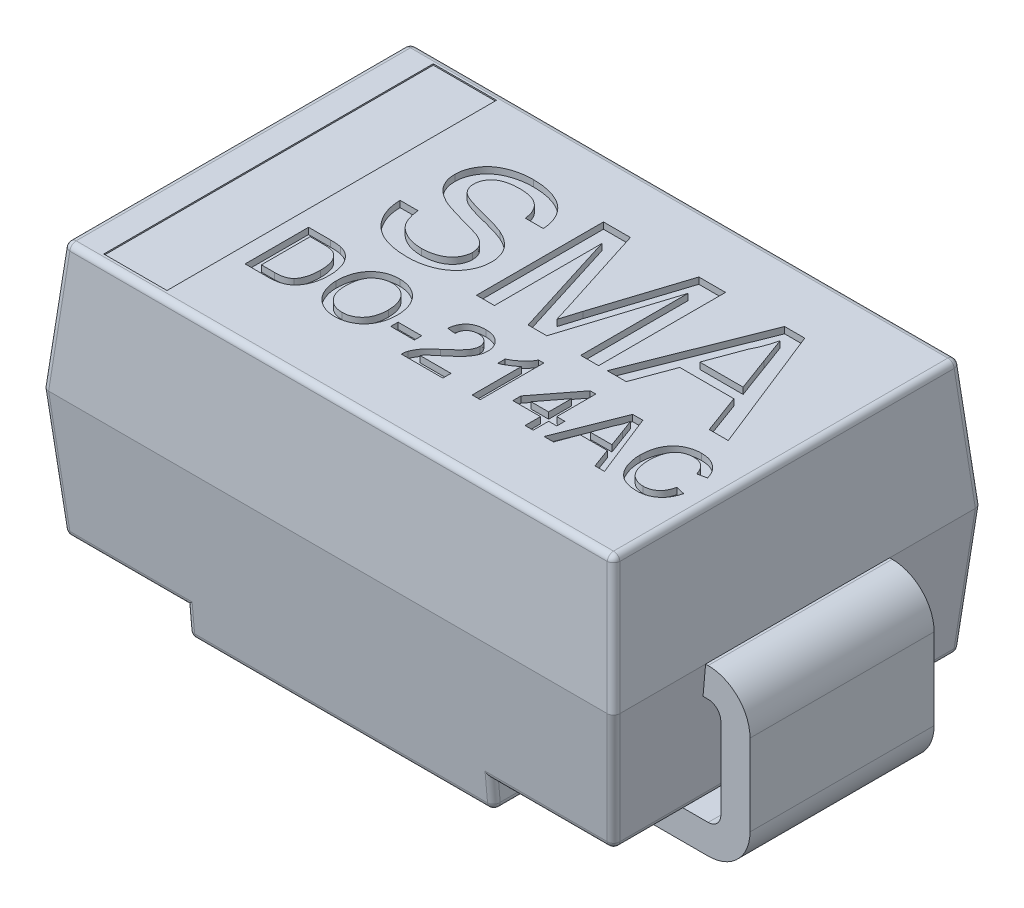
from build123d import *

# Parameters (mm, degrees)
BOSS_EXTRUDE1_START = 1.3
SKETCH1_W           = 4.5
SKETCH1_H           = 2.9
BOSS_EXTRUDE1_DEPTH = 1
BOSS_EXTRUDE1_TAPER = 5
BOSS_EXTRUDE2_START = 1.3
SKETCH1_2_W         = 4.5
SKETCH1_2_H         = 2.9
BOSS_EXTRUDE2_DEPTH = 1.23
BOSS_EXTRUDE2_DRAFT = -5
CUT_EXTRUDE2_DEPTH  = 2
BOSS_EXTRUDE3_DEPTH = 0.725
FILLET1_R           = 0.05
SKETCH5_W           = 0.498176358
SKETCH5_H           = 2.595911432
CUT_EXTRUDE4_DEPTH  = 0.01
SKETCH4_W           = 0.185897436
SKETCH4_H           = 0.057692308
CUT_EXTRUDE3_DEPTH  = 0.05


with BuildPart() as part:
    # Sketch1 → Boss-Extrude1 (new body)
    with BuildSketch(Plane(origin=(0, 0, 0), x_dir=(1, 0, 0), z_dir=(0, 1, 0)).offset(BOSS_EXTRUDE1_START)):
        Rectangle(SKETCH1_W, SKETCH1_H)
    extrude(amount=BOSS_EXTRUDE1_DEPTH, taper=BOSS_EXTRUDE1_TAPER)


with BuildPart() as boss_extrude2_tool:
    # Sketch1_2 → Boss-Extrude2 (with draft: the straight prism first)
    with BuildSketch(Plane(origin=(0, 0, 0), x_dir=(1, 0, 0), z_dir=(0, 1, 0)).offset(BOSS_EXTRUDE2_START)):
        Rectangle(SKETCH1_2_W, SKETCH1_2_H)
    extrude(amount=-BOSS_EXTRUDE2_DEPTH)
    # Boss-Extrude2: the draft: its side faces are tilted about the plane it starts from
    boss_extrude2_sides = [boss_extrude2_tool.faces().sort_by_distance(p)[0] for p in [
        (0, 0.685, 1.45),
        (2.25, 0.685, 0),
        (0, 0.685, -1.45),
        (-2.25, 0.685, 0),
    ]]
    draft(boss_extrude2_sides, Plane(origin=(0, 0, 0), x_dir=(1, 0, 0), z_dir=(0, 1, 0)).offset(BOSS_EXTRUDE2_START), BOSS_EXTRUDE2_DRAFT)


with BuildPart() as part_1:
    add(part.part)

    # Boss-Extrude2: add boss_extrude2_tool
    add(boss_extrude2_tool.part)

    # Sketch3 → Cut-Extrude2 (cut, symmetric)
    with BuildSketch(Plane.XY):
        Polygon((1.203776107, 0), (-1.203776107, 0), (-1.203776107, 0.297017544), (-2.27, 0.297017544), (-2.27, -0.205171261), (2.27, -0.205171261), (2.27, 0.297017544), (1.203776107, 0.297017544), align=None)
    extrude(amount=CUT_EXTRUDE2_DEPTH, both=True, mode=Mode.SUBTRACT)

    # Sketch2 → Boss-Extrude3 (add, symmetric)
    with BuildSketch(Plane.XY):
        with BuildLine():
            Line((2.27, 1.3), (-2.27, 1.3))
            ThreePointArc((-2.27, 1.3), (-2.503345238, 1.203345238), (-2.6, 0.97))
            Line((-2.6, 0.97), (-2.6, 0.33))
            ThreePointArc((-2.6, 0.33), (-2.503345238, 0.096654762), (-2.27, 0))
            Line((-2.27, 0), (-1.36, 0))
            Line((-1.36, 0), (-1.36, 0.23))
            Line((-1.36, 0.23), (-2.27, 0.23))
            ThreePointArc((-2.27, 0.23), (-2.340710678, 0.259289322), (-2.37, 0.33))
            Line((-2.37, 0.33), (-2.37, 0.97))
            ThreePointArc((-2.37, 0.97), (-2.340710678, 1.040710678), (-2.27, 1.07))
            Line((-2.27, 1.07), (2.27, 1.07))
            ThreePointArc((2.27, 1.07), (2.340710678, 1.040710678), (2.37, 0.97))
            Line((2.37, 0.97), (2.37, 0.33))
            ThreePointArc((2.37, 0.33), (2.340710678, 0.259289322), (2.27, 0.23))
            Line((2.27, 0.23), (1.36, 0.23))
            Line((1.36, 0.23), (1.36, 0))
            Line((1.36, 0), (2.27, 0))
            ThreePointArc((2.27, 0), (2.503345238, 0.096654762), (2.6, 0.33))
            Line((2.6, 0.33), (2.6, 0.97))
            ThreePointArc((2.6, 0.97), (2.503345238, 1.203345238), (2.27, 1.3))
        make_face()
    extrude(amount=BOSS_EXTRUDE3_DEPTH, both=True)

    # Fillet1
    fillet1_edges = [part_1.edges().sort_by_distance(p)[0] for p in [
        (0, 2.3, 1.362511336),
        (-2.162511336, 2.3, 0),
        (0, 2.3, -1.362511336),
        (2.162511336, 2.3, 0),
        (-1.683013256, 0.297017544, -1.362250405),
        (-1.203776107, 0.183508772, -1.352319675),
        (0, 0.07, -1.342388944),
        (1.203776107, 0.183508772, -1.352319675),
        (1.683013256, 0.297017544, -1.362250405),
        (1.203776107, 0.07, 0),
        (-1.203776107, 0.07, 0),
        (1.683013256, 0.297017544, 1.362250405),
        (1.203776107, 0.183508772, 1.352319675),
        (0, 0.07, 1.342388944),
        (-1.203776107, 0.183508772, 1.352319675),
        (-1.683013256, 0.297017544, 1.362250405),
        (-2.162250405, 0.297017544, 0),
        (2.162250405, 0.297017544, 0),
        (2.206125203, 0.798508772, -1.406125203),
        (2.206255668, 1.8, -1.406255668),
        (2.206255668, 1.8, 1.406255668),
        (2.206125203, 0.798508772, 1.406125203),
        (-2.206125203, 0.798508772, 1.406125203),
        (-2.206125203, 0.798508772, -1.406125203),
        (-2.206255668, 1.8, -1.406255668),
        (-2.206255668, 1.8, 1.406255668),
    ]]
    fillet(fillet1_edges, radius=FILLET1_R)

    # Sketch5 → Cut-Extrude4 (cut)
    with BuildSketch(Plane(origin=(0, 2.3, 0), x_dir=(1, 0, 0), z_dir=(0, 1, 0))):
        with Locations((-1.669039265, 0)):
            Rectangle(SKETCH5_W, SKETCH5_H)
    extrude(amount=-CUT_EXTRUDE4_DEPTH, mode=Mode.SUBTRACT)

    # Sketch4 → Cut-Extrude3 (cut)
    # profile 1 of 11: a face of its own
    with BuildSketch(Plane(origin=(0, 2.3, 0), x_dir=(1, 0, 0), z_dir=(0, 1, 0))):
        with BuildLine():
            Line((-1.117518154, 0.235376904), (-0.976492513, 0.235376904))
            add(Edge.make_bspline(
                [(-0.976492513, 0.235376904), (-0.974941313, 0.22271474), (-0.971961374, 0.198390043), (-0.963629166, 0.163913446), (-0.952905078, 0.132915447), (-0.939543159, 0.104984648), (-0.921966063, 0.080455937), (-0.900788687, 0.058331415), (-0.875069916, 0.039172918), (-0.846039286, 0.022123111), (-0.813707267, 0.008736316), (-0.779189952, -0.001187535), (-0.74265196, -0.007067496), (-0.717632992, -0.007825692), (-0.704857898, -0.00821284)],
                knots=[0, 0, 0, 0, 1.125557648, 2.162256852, 3.1243583, 4.018160113, 4.88511607, 5.777380551, 6.711250965, 7.707237736, 8.743031335, 9.791730543, 10.872421559, 12, 12, 12, 12], degree=3))
            add(Edge.make_bspline(
                [(-0.704857898, -0.00821284), (-0.69355304, -0.008003599), (-0.671510757, -0.00759562), (-0.63962413, -0.002694779), (-0.609618721, 0.004256932), (-0.582052963, 0.014772484), (-0.557028542, 0.02754166), (-0.535297636, 0.042986279), (-0.516744945, 0.060403566), (-0.502216843, 0.080252283), (-0.490803856, 0.101050419), (-0.48243125, 0.122428759), (-0.47744386, 0.144268641), (-0.476808337, 0.15896364), (-0.476492513, 0.166266327)],
                knots=[0, 0, 0, 0, 1.267006637, 2.470417599, 3.611360613, 4.716023143, 5.771382139, 6.754486395, 7.697536124, 8.612899418, 9.501261124, 10.352596716, 11.181322154, 12, 12, 12, 12], degree=3))
            add(Edge.make_bspline(
                [(-0.476492513, 0.166266327), (-0.476830135, 0.173495042), (-0.477490015, 0.187623554), (-0.481790271, 0.208192904), (-0.489963516, 0.227019833), (-0.500569241, 0.24487277), (-0.515323615, 0.261195413), (-0.533964102, 0.276235272), (-0.556901398, 0.289870554), (-0.574020638, 0.29733803), (-0.583063026, 0.301282353)],
                knots=[0, 0, 0, 0, 0.942140154, 1.841411588, 2.718743672, 3.605002079, 4.535543111, 5.568170452, 6.715506882, 8, 8, 8, 8], degree=3))
            add(Edge.make_bspline(
                [(-0.583063026, 0.301282353), (-0.586586074, 0.302728095), (-0.59454528, 0.305994291), (-0.608186985, 0.310318171), (-0.624374596, 0.315909389), (-0.643497007, 0.321667434), (-0.665451847, 0.327758641), (-0.690202563, 0.334652963), (-0.717735326, 0.341984697), (-0.747269259, 0.349788529), (-0.777089531, 0.35772383), (-0.805579318, 0.365666562), (-0.831791275, 0.373729453), (-0.855940116, 0.381492903), (-0.877901341, 0.389288383), (-0.897737282, 0.396902469), (-0.915472669, 0.404180681), (-0.926304768, 0.409532238), (-0.931420398, 0.412059596)],
                knots=[0, 0, 0, 0, 0.499201778, 1.127787504, 1.87543728, 2.745208432, 3.745951656, 4.863402235, 6.114490242, 7.482339553, 8.869366102, 10.161191451, 11.360587006, 12.46547846, 13.487450326, 14.41601931, 15.251940103, 16, 16, 16, 16], degree=3))
            add(Edge.make_bspline(
                [(-0.931420398, 0.412059596), (-0.943190035, 0.418417893), (-0.965908499, 0.430691062), (-0.996485035, 0.452635521), (-1.02224887, 0.476986961), (-1.043091313, 0.503710069), (-1.059424719, 0.532352896), (-1.070444797, 0.562964132), (-1.077992641, 0.594988128), (-1.078698007, 0.617009646), (-1.079056616, 0.628205429)],
                knots=[0, 0, 0, 0, 1.158441928, 2.236094408, 3.251151369, 4.220012324, 5.163146324, 6.095083285, 7.031536583, 8, 8, 8, 8], degree=3))
            add(Edge.make_bspline(
                [(-1.079056616, 0.628205429), (-1.07858067, 0.640602868), (-1.077634017, 0.665261284), (-1.069236687, 0.701445972), (-1.055842786, 0.736265266), (-1.040596458, 0.763908815), (-1.025727919, 0.784812743), (-1.013401787, 0.79986737), (-0.99957562, 0.813783348), (-0.984675214, 0.826754936), (-0.968434211, 0.838588323), (-0.951255551, 0.849769846), (-0.932517463, 0.859380633), (-0.906187662, 0.871612996), (-0.870964733, 0.883828154), (-0.826623471, 0.894472115), (-0.779955749, 0.900740123), (-0.748145933, 0.901602942), (-0.731901167, 0.90204357)],
                knots=[0, 0, 0, 0, 1.199927478, 2.386647047, 3.578628709, 4.806592355, 5.433127754, 6.062729195, 6.689531802, 7.331674828, 7.974827539, 8.635320743, 9.315455226, 10.01318112, 11.447700238, 12.918145351, 14.426146008, 16, 16, 16, 16], degree=3))
            add(Edge.make_bspline(
                [(-0.731901167, 0.90204357), (-0.714120192, 0.901636147), (-0.679497208, 0.900842814), (-0.629189034, 0.894242429), (-0.58226528, 0.882907833), (-0.545466062, 0.870219889), (-0.51826083, 0.857375067), (-0.498933476, 0.847352383), (-0.480993869, 0.835764334), (-0.464280518, 0.823224253), (-0.448638177, 0.809737866), (-0.43446889, 0.794984376), (-0.421157387, 0.779467147), (-0.405514515, 0.757189267), (-0.388648184, 0.727704619), (-0.374064944, 0.689506086), (-0.364046089, 0.649190671), (-0.362097191, 0.621319593), (-0.361107898, 0.607171776)],
                knots=[0, 0, 0, 0, 1.607600973, 3.130308851, 4.577334065, 5.967726088, 6.640410691, 7.296826776, 7.935019992, 8.569057421, 9.185393759, 9.8003086, 10.417295362, 11.032210203, 12.259799365, 13.477607022, 14.719591916, 16, 16, 16, 16], degree=3))
            Line((-0.361107898, 0.607171776), (-0.502133539, 0.607171776))
            add(Edge.make_bspline(
                [(-0.502133539, 0.607171776), (-0.503029595, 0.614332399), (-0.504782911, 0.628343618), (-0.509132656, 0.648626965), (-0.515230124, 0.667465225), (-0.522372126, 0.685034077), (-0.531029729, 0.701150787), (-0.541121988, 0.715970109), (-0.552771807, 0.729317447), (-0.565679423, 0.741545489), (-0.580237612, 0.7521927), (-0.59637157, 0.761434806), (-0.614108531, 0.769242269), (-0.63343287, 0.775636836), (-0.654348412, 0.780594934), (-0.67690273, 0.784242205), (-0.701087106, 0.786110135), (-0.717742509, 0.786472793), (-0.726292193, 0.786658955)],
                knots=[0, 0, 0, 0, 1.074487479, 2.102453544, 3.083708351, 4.020042547, 4.923259678, 5.803182661, 6.684453325, 7.556870173, 8.445961597, 9.363679789, 10.320905216, 11.327237703, 12.390948353, 13.519046902, 14.726457512, 16, 16, 16, 16], degree=3))
            add(Edge.make_bspline(
                [(-0.726292193, 0.786658955), (-0.73517919, 0.786591969), (-0.752382231, 0.786462301), (-0.777251177, 0.784098608), (-0.800301476, 0.780855538), (-0.821493535, 0.776071733), (-0.840757934, 0.769809717), (-0.858380582, 0.762578526), (-0.873868291, 0.753414718), (-0.887582108, 0.743207427), (-0.899412011, 0.731913624), (-0.909607635, 0.720012686), (-0.918624878, 0.707854271), (-0.925631474, 0.694773793), (-0.931335896, 0.681266629), (-0.935015875, 0.667078888), (-0.937621387, 0.652473007), (-0.937892559, 0.642507122), (-0.938030975, 0.637420173)],
                knots=[0, 0, 0, 0, 1.464176581, 2.834285765, 4.113735764, 5.29917439, 6.409476712, 7.449999357, 8.431575861, 9.367089851, 10.262376129, 11.120706676, 11.948504824, 12.751342953, 13.560717798, 14.359016663, 15.162382702, 16, 16, 16, 16], degree=3))
            add(Edge.make_bspline(
                [(-0.938030975, 0.637420173), (-0.937666531, 0.628816613), (-0.93695918, 0.612117895), (-0.929736091, 0.588394051), (-0.918626929, 0.56676823), (-0.907682635, 0.555001731), (-0.902173603, 0.549078827)],
                knots=[0, 0, 0, 0, 1.050964922, 2.039826012, 3.013306874, 4, 4, 4, 4], degree=3))
            add(Edge.make_bspline(
                [(-0.902173603, 0.549078827), (-0.898700768, 0.546118843), (-0.891020809, 0.53957302), (-0.87673106, 0.53091039), (-0.859013891, 0.522157907), (-0.837750919, 0.513457262), (-0.812978726, 0.504702829), (-0.784737272, 0.495689063), (-0.752918988, 0.486736709), (-0.718493534, 0.478109635), (-0.683715799, 0.469447879), (-0.650665258, 0.460819135), (-0.620319268, 0.452641461), (-0.592725973, 0.444665479), (-0.567856815, 0.436913743), (-0.545798222, 0.429223844), (-0.526371732, 0.422151087), (-0.514470712, 0.417174826), (-0.508944436, 0.414864083)],
                knots=[0, 0, 0, 0, 0.523891492, 1.158553688, 1.913783773, 2.794766643, 3.797521443, 4.933638669, 6.202080764, 7.596537849, 9.013317056, 10.322179469, 11.523240428, 12.626146501, 13.623953177, 14.517289671, 15.311498917, 16, 16, 16, 16], degree=3))
            add(Edge.make_bspline(
                [(-0.508944436, 0.414864083), (-0.501754472, 0.411549048), (-0.487641777, 0.405042189), (-0.467649254, 0.393932707), (-0.448994061, 0.382396107), (-0.43182692, 0.370121786), (-0.41620334, 0.357083926), (-0.401948632, 0.34343191), (-0.388976701, 0.329242466), (-0.377810964, 0.31406145), (-0.367785278, 0.298502545), (-0.359012135, 0.282348297), (-0.351948169, 0.265503705), (-0.34575263, 0.248171815), (-0.341296261, 0.230159847), (-0.337801568, 0.211649732), (-0.335763172, 0.192554469), (-0.335566493, 0.179625767), (-0.335466872, 0.173077224)],
                knots=[0, 0, 0, 0, 1.198900896, 2.353241543, 3.461831299, 4.520043694, 5.547003373, 6.541368882, 7.508191797, 8.454912692, 9.392021408, 10.310662301, 11.235020644, 12.156274873, 13.095836685, 14.042125239, 15.00831306, 16, 16, 16, 16], degree=3))
            add(Edge.make_bspline(
                [(-0.335466872, 0.173077224), (-0.335988753, 0.160008114), (-0.337024861, 0.134061585), (-0.345946119, 0.095815202), (-0.359960943, 0.058754671), (-0.376396797, 0.029345098), (-0.391933646, 0.006880458), (-0.404985332, -0.009266099), (-0.419458902, -0.024196051), (-0.43499803, -0.038377125), (-0.451723364, -0.051519982), (-0.469775908, -0.063629096), (-0.488965127, -0.074830523), (-0.516366849, -0.088480118), (-0.552760887, -0.10275889), (-0.599119587, -0.114649768), (-0.647976041, -0.122363674), (-0.681523898, -0.123180511), (-0.698647962, -0.123597455)],
                knots=[0, 0, 0, 0, 1.197055466, 2.376552968, 3.581957237, 4.820753935, 5.454298064, 6.085440993, 6.72202542, 7.359198513, 8.013298489, 8.67051481, 9.351020706, 10.049282741, 11.476266879, 12.925760103, 14.430794493, 16, 16, 16, 16], degree=3))
            add(Edge.make_bspline(
                [(-0.698647962, -0.123597455), (-0.709535798, -0.123507604), (-0.730863512, -0.123331598), (-0.762202207, -0.121200109), (-0.79223465, -0.118116806), (-0.820931371, -0.113524192), (-0.848202377, -0.107498932), (-0.874145561, -0.100263759), (-0.898822414, -0.091930966), (-0.922146716, -0.082131745), (-0.944057579, -0.070746121), (-0.964948983, -0.058463914), (-0.984479445, -0.044541456), (-1.002690079, -0.029197518), (-1.020042302, -0.012875373), (-1.035816917, 0.005091563), (-1.050550222, 0.024177871), (-1.063905563, 0.044558237), (-1.075836527, 0.065966018), (-1.086565863, 0.088041693), (-1.095605479, 0.110945405), (-1.102890549, 0.134561397), (-1.109061372, 0.158731633), (-1.113340695, 0.18365777), (-1.116486998, 0.209261549), (-1.117172405, 0.226620367), (-1.117518154, 0.235376904)],
                knots=[0, 0, 0, 0, 1.259822038, 2.467811403, 3.633536148, 4.752793854, 5.829021491, 6.863980041, 7.868367876, 8.841470325, 9.788447787, 10.724101269, 11.643985084, 12.560193707, 13.478453146, 14.398077254, 15.323914234, 16.266973849, 17.21495974, 18.158525798, 19.105629373, 20.061269543, 21.017128399, 21.990322895, 22.986232211, 24, 24, 24, 24], degree=3))
        make_face()
    # profile 2 of 11: a face of its own
    with BuildSketch(Plane(origin=(0, 2.3, 0), x_dir=(1, 0, 0), z_dir=(0, 1, 0))):
        with BuildLine():
            Line((-0.168800206, -0.110776942), (-0.168800206, 0.889223058))
            Line((-0.168800206, 0.889223058), (0.043339217, 0.889223058))
            Line((0.043339217, 0.889223058), (0.26689691, 0.187500301))
            add(Edge.make_bspline(
                [(0.26689691, 0.187500301), (0.269357172, 0.179551005), (0.274115175, 0.16417753), (0.281170729, 0.141976816), (0.287590101, 0.12134623), (0.293371756, 0.102220101), (0.298827979, 0.084693392), (0.303552208, 0.068622281), (0.308068724, 0.054185356), (0.310715605, 0.045010217), (0.311969025, 0.040665365)],
                knots=[0, 0, 0, 0, 1.300204174, 2.514519184, 3.639827924, 4.676153899, 5.636536826, 6.507959918, 7.293450077, 8, 8, 8, 8], degree=3))
            add(Edge.make_bspline(
                [(0.311969025, 0.040665365), (0.313365044, 0.045408151), (0.316335862, 0.055501103), (0.321152033, 0.071370539), (0.326276576, 0.088931856), (0.332409083, 0.107883203), (0.338801495, 0.128521867), (0.345511165, 0.15083071), (0.353250637, 0.174587002), (0.358393904, 0.191033849), (0.361047551, 0.199519532)],
                knots=[0, 0, 0, 0, 0.713638162, 1.518667645, 2.393860736, 3.354087503, 4.393659122, 5.512594909, 6.716633584, 8, 8, 8, 8], degree=3))
            Line((0.361047551, 0.199519532), (0.582401717, 0.889223058))
            Line((0.582401717, 0.889223058), (0.792738256, 0.889223058))
            Line((0.792738256, 0.889223058), (0.792738256, -0.110776942))
            Line((0.792738256, -0.110776942), (0.651712615, -0.110776942))
            Line((0.651712615, -0.110776942), (0.651712615, 0.735376904))
            Line((0.651712615, 0.735376904), (0.384885692, -0.110776942))
            Line((0.384885692, -0.110776942), (0.237449794, -0.110776942))
            Line((0.237449794, -0.110776942), (-0.027774565, 0.735376904))
            Line((-0.027774565, 0.735376904), (-0.027774565, -0.110776942))
            Line((-0.027774565, -0.110776942), (-0.168800206, -0.110776942))
        make_face()
    # profile 3 of 11: a face of its own
    with BuildSketch(Plane(origin=(0, 2.3, 0), x_dir=(1, 0, 0), z_dir=(0, 1, 0))):
        Polygon((0.861047551, -0.110776942), (1.258082807, 0.889223058), (1.417137294, 0.889223058), (1.814172551, -0.110776942), (1.664533128, -0.110776942), (1.550751076, 0.196915365), (1.124469025, 0.196915365), (1.010686974, -0.110776942), align=None)
        with BuildLine():
            Line((1.166936974, 0.312299981), (1.508283128, 0.312299981))
            Line((1.508283128, 0.312299981), (1.411127679, 0.575120494))
            add(Edge.make_bspline(
                [(1.411127679, 0.575120494), (1.407403086, 0.58527552), (1.400120803, 0.605130514), (1.389260726, 0.633978144), (1.379339134, 0.661373038), (1.369610199, 0.686922392), (1.360827715, 0.710997336), (1.352732675, 0.733435254), (1.344726748, 0.754080193), (1.339922279, 0.76741895), (1.337610051, 0.773838442)],
                knots=[0, 0, 0, 0, 1.225184869, 2.395467751, 3.491410812, 4.525364584, 5.492066482, 6.394148129, 7.227157926, 8, 8, 8, 8], degree=3))
            add(Edge.make_bspline(
                [(1.337610051, 0.773838442), (1.333785179, 0.758008541), (1.326119665, 0.726283465), (1.310069943, 0.679801975), (1.29170962, 0.633745578), (1.27679885, 0.60406715), (1.269300756, 0.589142929)],
                knots=[0, 0, 0, 0, 0.9891762, 1.982431084, 2.985436691, 4, 4, 4, 4], degree=3))
            Line((1.269300756, 0.589142929), (1.166936974, 0.312299981))
        make_face(mode=Mode.SUBTRACT)
    # profile 4 of 11: a face of its own
    with BuildSketch(Plane(origin=(0, 2.3, 0), x_dir=(1, 0, 0), z_dir=(0, 1, 0))):
        with BuildLine():
            Line((-1.293786389, -0.808671679), (-1.293786389, -0.308671679))
            Line((-1.293786389, -0.308671679), (-1.122812831, -0.308671679))
            add(Edge.make_bspline(
                [(-1.122812831, -0.308671679), (-1.118138642, -0.308692795), (-1.109056335, -0.308733826), (-1.095863361, -0.30899533), (-1.083509912, -0.309626075), (-1.072052913, -0.310394406), (-1.06143458, -0.311417372), (-1.051668478, -0.312561303), (-1.042746988, -0.314053412), (-1.03713795, -0.315293633), (-1.034471485, -0.315883218)],
                knots=[0, 0, 0, 0, 1.263127796, 2.454354013, 3.565393221, 4.605443485, 5.557051711, 6.447822442, 7.26211484, 8, 8, 8, 8], degree=3))
            add(Edge.make_bspline(
                [(-1.034471485, -0.315883218), (-1.027575549, -0.317692447), (-1.014027808, -0.321246855), (-0.994903746, -0.329242037), (-0.977347025, -0.339270534), (-0.966934785, -0.347531133), (-0.961755139, -0.351640429)],
                knots=[0, 0, 0, 0, 1.04477941, 2.052571232, 3.03123721, 4, 4, 4, 4], degree=3))
            add(Edge.make_bspline(
                [(-0.961755139, -0.351640429), (-0.958539127, -0.35446461), (-0.952092544, -0.360125756), (-0.943238201, -0.369452907), (-0.935024173, -0.379347499), (-0.927205121, -0.389639187), (-0.920281142, -0.40070318), (-0.913790884, -0.412221027), (-0.908129807, -0.424424021), (-0.902918872, -0.43711273), (-0.898276283, -0.45033661), (-0.89446163, -0.464087123), (-0.890957177, -0.47822068), (-0.888350679, -0.492891776), (-0.88607534, -0.50797597), (-0.884630894, -0.523559598), (-0.883693688, -0.539596139), (-0.88358508, -0.550457143), (-0.883529979, -0.555967352)],
                knots=[0, 0, 0, 0, 0.908997367, 1.822109427, 2.728529095, 3.640759027, 4.565643067, 5.499218265, 6.448003669, 7.421473682, 8.413047621, 9.423472075, 10.452328391, 11.505545429, 12.587978234, 13.692612971, 14.829372988, 16, 16, 16, 16], degree=3))
            add(Edge.make_bspline(
                [(-0.883529979, -0.555967352), (-0.88366429, -0.565188579), (-0.883925656, -0.58313287), (-0.886510469, -0.609232506), (-0.890510248, -0.63376531), (-0.896331359, -0.656583969), (-0.903500666, -0.677561923), (-0.911321757, -0.696870504), (-0.920324389, -0.714177007), (-0.930200074, -0.729627728), (-0.940781609, -0.743320425), (-0.951867023, -0.755460603), (-0.963489177, -0.766053633), (-0.975589033, -0.775377519), (-0.988795003, -0.783097952), (-1.002968545, -0.790030252), (-1.018569495, -0.795600351), (-1.035304056, -0.800472641), (-1.053368785, -0.804122842), (-1.072665859, -0.806805128), (-1.093271118, -0.80842714), (-1.107418543, -0.808588587), (-1.114699851, -0.808671679)],
                knots=[0, 0, 0, 0, 1.410753827, 2.745293735, 4.009435601, 5.211453015, 6.344066657, 7.400119332, 8.396481539, 9.324811333, 10.202671465, 11.041621015, 11.837259285, 12.606727868, 13.374311266, 14.17412185, 15.017911533, 15.905707008, 16.839601966, 17.835295848, 18.885883805, 20, 20, 20, 20], degree=3))
            Line((-1.114699851, -0.808671679), (-1.293786389, -0.808671679))
        make_face()
        with BuildLine():
            Line((-1.223273569, -0.750979372), (-1.120208665, -0.750979372))
            add(Edge.make_bspline(
                [(-1.120208665, -0.750979372), (-1.112693428, -0.750866871), (-1.098476275, -0.750654046), (-1.078418118, -0.749019556), (-1.060911969, -0.74620028), (-1.045763704, -0.742189212), (-1.032620219, -0.737002284), (-1.021047317, -0.730870097), (-1.010753076, -0.723911442), (-1.004954329, -0.718344227), (-1.002119722, -0.715622801)],
                knots=[0, 0, 0, 0, 1.423649224, 2.693227144, 3.808972214, 4.778671344, 5.656058397, 6.479437267, 7.256702014, 8, 8, 8, 8], degree=3))
            add(Edge.make_bspline(
                [(-1.002119722, -0.715622801), (-0.998431047, -0.71140508), (-0.99085324, -0.70274043), (-0.981416905, -0.687603747), (-0.973187962, -0.670572081), (-0.966309033, -0.651464118), (-0.960668489, -0.63034449), (-0.956906461, -0.607024024), (-0.954446816, -0.58166129), (-0.954180825, -0.564019916), (-0.954042799, -0.554865589)],
                knots=[0, 0, 0, 0, 0.782184731, 1.606876467, 2.483531085, 3.422528604, 4.441347086, 5.534669947, 6.720709839, 8, 8, 8, 8], degree=3))
            add(Edge.make_bspline(
                [(-0.954042799, -0.554865589), (-0.954128319, -0.548487666), (-0.954294566, -0.53608924), (-0.955330976, -0.518026813), (-0.957377, -0.501122189), (-0.959993674, -0.485346128), (-0.963566332, -0.470748778), (-0.967651728, -0.457190281), (-0.972791297, -0.444847878), (-0.978656174, -0.433626286), (-0.985090012, -0.423450983), (-0.991794303, -0.414103409), (-0.998803356, -0.405614212), (-1.006265686, -0.398104178), (-1.013956967, -0.391351218), (-1.022020586, -0.385493589), (-1.030433978, -0.380533089), (-1.036346014, -0.377958055), (-1.039279178, -0.376680493)],
                knots=[0, 0, 0, 0, 1.460126857, 2.838427476, 4.139102445, 5.35666337, 6.496721546, 7.577303074, 8.594995104, 9.55219858, 10.472533725, 11.348579167, 12.184287935, 12.989560785, 13.769667798, 14.524891986, 15.268148459, 16, 16, 16, 16], degree=3))
            add(Edge.make_bspline(
                [(-1.039279178, -0.376680493), (-1.041571035, -0.375841773), (-1.046427331, -0.374064578), (-1.054353276, -0.372053062), (-1.063198711, -0.370201909), (-1.073050823, -0.368902642), (-1.083859784, -0.367639895), (-1.095692782, -0.366872551), (-1.108487759, -0.36652481), (-1.117337225, -0.366418788), (-1.121911389, -0.366363987)],
                knots=[0, 0, 0, 0, 0.699400087, 1.48198292, 2.341906832, 3.289648813, 4.329964754, 5.462247508, 6.688271602, 8, 8, 8, 8], degree=3))
            Line((-1.121911389, -0.366363987), (-1.223273569, -0.366363987))
            Line((-1.223273569, -0.366363987), (-1.223273569, -0.750979372))
        make_face(mode=Mode.SUBTRACT)
    # profile 5 of 11: a face of its own
    with BuildSketch(Plane(origin=(0, 2.3, 0), x_dir=(1, 0, 0), z_dir=(0, 1, 0))):
        with BuildLine():
            add(Edge.make_bspline(
                [(-0.819427415, -0.565282256), (-0.819253634, -0.555257687), (-0.818915031, -0.535725323), (-0.815751281, -0.507283683), (-0.810614162, -0.480523821), (-0.803270197, -0.455447821), (-0.7939617, -0.432016388), (-0.782645443, -0.410176466), (-0.768981042, -0.390175267), (-0.753523122, -0.371822392), (-0.736257336, -0.355597106), (-0.71787418, -0.341186727), (-0.698144108, -0.329166767), (-0.67724941, -0.319242243), (-0.655101314, -0.311622481), (-0.631762004, -0.306287954), (-0.607256442, -0.302846666), (-0.590506317, -0.302459337), (-0.581947447, -0.302261423)],
                knots=[0, 0, 0, 0, 1.203621547, 2.345195544, 3.432004029, 4.472479546, 5.478447225, 6.455936844, 7.420185704, 8.381829745, 9.332027588, 10.260832629, 11.182364398, 12.100723901, 13.034044877, 13.989196293, 14.972532542, 16, 16, 16, 16], degree=3))
            add(Edge.make_bspline(
                [(-0.581947447, -0.302261423), (-0.576302284, -0.302359998), (-0.56509201, -0.30255575), (-0.548518622, -0.304045165), (-0.532371112, -0.306703513), (-0.51666538, -0.310265997), (-0.501358677, -0.314939821), (-0.48644186, -0.320457127), (-0.472045511, -0.327293847), (-0.458073854, -0.334948236), (-0.444691814, -0.34351), (-0.432115406, -0.352968164), (-0.420374755, -0.363251196), (-0.409312152, -0.37419007), (-0.399296741, -0.386153958), (-0.389914758, -0.398778421), (-0.381435803, -0.412287309), (-0.373829787, -0.426569941), (-0.367029237, -0.441405724), (-0.361216854, -0.456856147), (-0.356225866, -0.472735869), (-0.352047988, -0.489138884), (-0.349050248, -0.506059582), (-0.346663115, -0.523425055), (-0.345406702, -0.541292058), (-0.345182145, -0.553361537), (-0.34506844, -0.559472961)],
                knots=[0, 0, 0, 0, 1.034375294, 2.054082248, 3.045783978, 4.031219655, 5.002789406, 5.976610191, 6.94273282, 7.920236376, 8.894345378, 9.851183672, 10.800797181, 11.752517031, 12.698794154, 13.65688337, 14.632873302, 15.61821402, 16.620222298, 17.621258913, 18.640965868, 19.669244166, 20.720417492, 21.788124603, 22.880008887, 24, 24, 24, 24], degree=3))
            add(Edge.make_bspline(
                [(-0.34506844, -0.559472961), (-0.345172619, -0.565685163), (-0.345378441, -0.577958439), (-0.346771121, -0.596089823), (-0.349219935, -0.613700692), (-0.35246787, -0.63084356), (-0.356820004, -0.647482737), (-0.361991846, -0.66366593), (-0.368247481, -0.679296749), (-0.375312527, -0.694412866), (-0.383306623, -0.708806383), (-0.392124654, -0.722376654), (-0.401772866, -0.734996739), (-0.412104704, -0.746821454), (-0.423361444, -0.757639352), (-0.435404474, -0.767551588), (-0.44818749, -0.776651645), (-0.461753435, -0.784693066), (-0.475858851, -0.791741659), (-0.490224613, -0.79799503), (-0.504861392, -0.803328154), (-0.519819213, -0.807650121), (-0.535057272, -0.810916111), (-0.550532687, -0.813361718), (-0.566296189, -0.814769907), (-0.576903358, -0.814977392), (-0.582247928, -0.815081936)],
                knots=[0, 0, 0, 0, 1.141429366, 2.255090526, 3.338676798, 4.407031443, 5.458968682, 6.496860253, 7.526652771, 8.550250826, 9.560787671, 10.54935636, 11.521089193, 12.477323897, 13.431786008, 14.386110112, 15.340986122, 16.312041, 17.28047646, 18.236612773, 19.189437236, 20.140779471, 21.09494583, 22.051062463, 23.018000708, 24, 24, 24, 24], degree=3))
            add(Edge.make_bspline(
                [(-0.582247928, -0.815081936), (-0.587994527, -0.814996914), (-0.599377101, -0.814828507), (-0.616200853, -0.813147522), (-0.632606056, -0.810583121), (-0.648545017, -0.806880901), (-0.663995958, -0.802051093), (-0.678977159, -0.796205246), (-0.693541311, -0.789421489), (-0.707507697, -0.781505579), (-0.720828782, -0.772703938), (-0.733375452, -0.763060319), (-0.74514077, -0.752663596), (-0.75593595, -0.741341923), (-0.766110614, -0.729505717), (-0.775257934, -0.716715031), (-0.783676647, -0.703259946), (-0.791117629, -0.68901076), (-0.797839443, -0.674390906), (-0.803502717, -0.659395706), (-0.808479636, -0.64424615), (-0.812443249, -0.628848863), (-0.815601766, -0.613239362), (-0.81772564, -0.597443622), (-0.819259518, -0.581438116), (-0.819371167, -0.570694643), (-0.819427415, -0.565282256)],
                knots=[0, 0, 0, 0, 1.072727997, 2.12480551, 3.153819198, 4.171534612, 5.177148798, 6.173931848, 7.17235114, 8.174500385, 9.168706755, 10.151274001, 11.127173509, 12.097141049, 13.070188938, 14.039134204, 15.03036519, 16.031505612, 17.038625933, 18.033164522, 19.022845559, 20.014762458, 21.000193215, 21.994692725, 22.989758729, 24, 24, 24, 24], degree=3))
        make_face()
        with BuildLine():
            add(Edge.make_bspline(
                [(-0.748914594, -0.566083538), (-0.748806537, -0.573302132), (-0.748595832, -0.587377882), (-0.746185257, -0.607899575), (-0.742527595, -0.627262839), (-0.737485894, -0.645522029), (-0.730708613, -0.662496565), (-0.722605496, -0.678349555), (-0.712903709, -0.692975619), (-0.701817302, -0.706333842), (-0.689623526, -0.718333868), (-0.676593239, -0.728815252), (-0.662723511, -0.73759267), (-0.648168114, -0.744840302), (-0.632822503, -0.75049774), (-0.616732637, -0.75447025), (-0.599886696, -0.756954733), (-0.588399841, -0.757242857), (-0.582548408, -0.757389628)],
                knots=[0, 0, 0, 0, 1.215430442, 2.370003584, 3.475209778, 4.53279855, 5.55522989, 6.548792651, 7.526809858, 8.505409025, 9.467826767, 10.404123909, 11.316848639, 12.227335424, 13.138360512, 14.065900994, 15.014765094, 16, 16, 16, 16], degree=3))
            add(Edge.make_bspline(
                [(-0.582548408, -0.757389628), (-0.576597794, -0.757240686), (-0.564946507, -0.756949058), (-0.54784659, -0.754507947), (-0.531599754, -0.750352058), (-0.516044965, -0.74481963), (-0.501463439, -0.737340729), (-0.487514153, -0.728582977), (-0.474577369, -0.717881255), (-0.462335525, -0.705860006), (-0.451355415, -0.692195649), (-0.441612879, -0.677224779), (-0.433698729, -0.660722873), (-0.426865928, -0.643053445), (-0.421862557, -0.623882536), (-0.41816476, -0.60342808), (-0.415936389, -0.581624281), (-0.41570173, -0.566656379), (-0.415581261, -0.55897216)],
                knots=[0, 0, 0, 0, 0.976878588, 1.912725521, 2.8289017, 3.727303729, 4.617335839, 5.514666588, 6.426584173, 7.368641557, 8.327632997, 9.299405846, 10.294892156, 11.327373912, 12.405931897, 13.542618837, 14.738430195, 16, 16, 16, 16], degree=3))
            add(Edge.make_bspline(
                [(-0.415581261, -0.55897216), (-0.415623835, -0.554028634), (-0.415707349, -0.544331225), (-0.416813358, -0.530037132), (-0.418239968, -0.516187668), (-0.420412004, -0.502800703), (-0.423405345, -0.489931675), (-0.426721459, -0.477482612), (-0.430868143, -0.465560794), (-0.435573134, -0.454119467), (-0.440837939, -0.443217369), (-0.44677594, -0.43294641), (-0.453318123, -0.423346519), (-0.460287974, -0.414235694), (-0.468071443, -0.405966561), (-0.476293752, -0.398189827), (-0.485141669, -0.391066161), (-0.494526897, -0.384593703), (-0.504316294, -0.37876747), (-0.514489678, -0.373780971), (-0.524884974, -0.369400958), (-0.535676183, -0.366043495), (-0.5467143, -0.363335651), (-0.558043948, -0.361278791), (-0.569707178, -0.360213654), (-0.577571922, -0.360040994), (-0.581546806, -0.35995373)],
                knots=[0, 0, 0, 0, 1.220438779, 2.394059227, 3.538503547, 4.658058814, 5.74010225, 6.800155734, 7.837851593, 8.854470756, 9.853724944, 10.825214244, 11.781044712, 12.72106398, 13.654479919, 14.581868691, 15.514082315, 16.456304431, 17.39516604, 18.324312202, 19.252140633, 20.177768678, 21.111585046, 22.057694709, 23.018348693, 24, 24, 24, 24], degree=3))
            add(Edge.make_bspline(
                [(-0.581546806, -0.35995373), (-0.587164761, -0.360065301), (-0.598249613, -0.360285442), (-0.614567835, -0.362732648), (-0.63030037, -0.366389109), (-0.645471634, -0.371501037), (-0.659951868, -0.378270032), (-0.673816095, -0.386571279), (-0.687187379, -0.396178746), (-0.699854874, -0.407326519), (-0.71166375, -0.420132589), (-0.72164697, -0.435230552), (-0.7300611, -0.45225999), (-0.737086744, -0.471177735), (-0.742443591, -0.492130295), (-0.746145842, -0.515027499), (-0.748483368, -0.539893477), (-0.748767177, -0.557130335), (-0.748914594, -0.566083538)],
                knots=[0, 0, 0, 0, 0.895090134, 1.766112571, 2.624765742, 3.468151641, 4.313618154, 5.168136083, 6.041303099, 6.935189387, 7.854749729, 8.809996334, 9.809869957, 10.877771942, 12.021723904, 13.25217762, 14.572720513, 16, 16, 16, 16], degree=3))
        make_face(mode=Mode.SUBTRACT)
    # profile 6 of 11: a face of its own
    with BuildSketch(Plane(origin=(0, 2.3, 0), x_dir=(1, 0, 0), z_dir=(0, 1, 0))):
        with Locations((-0.200837671, -0.632389628)):
            Rectangle(SKETCH4_W, SKETCH4_H)
    # profile 7 of 11: a face of its own
    with BuildSketch(Plane(origin=(0, 2.3, 0), x_dir=(1, 0, 0), z_dir=(0, 1, 0))):
        with BuildLine():
            Line((0.263905919, -0.744569115), (0.263905919, -0.808671679))
            Line((0.263905919, -0.808671679), (-0.063017158, -0.808671679))
            add(Edge.make_bspline(
                [(-0.063017158, -0.808671679), (-0.063023851, -0.804861884), (-0.063037215, -0.797255062), (-0.061750018, -0.786005055), (-0.05973401, -0.774904289), (-0.057454511, -0.76778581), (-0.056306421, -0.764200525)],
                knots=[0, 0, 0, 0, 1.01057331, 2.01775941, 3.001627217, 4, 4, 4, 4], degree=3))
            add(Edge.make_bspline(
                [(-0.056306421, -0.764200525), (-0.054185133, -0.758342598), (-0.049865842, -0.746414894), (-0.041114912, -0.729204883), (-0.03082175, -0.712098954), (-0.020799909, -0.698172313), (-0.011622066, -0.6870459), (-0.003925249, -0.67834077), (0.004604236, -0.669430043), (0.013959557, -0.660315348), (0.024050676, -0.650937652), (0.03489136, -0.64126568), (0.046609623, -0.631479681), (0.054790196, -0.624993114), (0.058978034, -0.62167248)],
                knots=[0, 0, 0, 0, 1.204657718, 2.452881516, 3.728232997, 5.065887527, 5.768225529, 6.518857853, 7.313994055, 8.154655305, 9.046094665, 9.979688118, 10.965752482, 12, 12, 12, 12], degree=3))
            add(Edge.make_bspline(
                [(0.058978034, -0.62167248), (0.065411587, -0.616257463), (0.077799801, -0.605830505), (0.095293901, -0.590357864), (0.111271914, -0.575990641), (0.125479407, -0.56247702), (0.138032584, -0.549948075), (0.14896092, -0.538432192), (0.158358445, -0.52796531), (0.166110434, -0.518168571), (0.172651025, -0.508917724), (0.178193598, -0.499894095), (0.182812597, -0.490940059), (0.186659606, -0.482083951), (0.189702263, -0.473287897), (0.191776266, -0.46452627), (0.193182783, -0.455886007), (0.193323506, -0.45013668), (0.193393098, -0.447293474)],
                knots=[0, 0, 0, 0, 1.782554561, 3.432421876, 4.950675607, 6.337395053, 7.588547463, 8.709982106, 9.702713005, 10.569305638, 11.356701089, 12.103210377, 12.812277205, 13.490692607, 14.148717897, 14.782152033, 15.397739362, 16, 16, 16, 16], degree=3))
            add(Edge.make_bspline(
                [(0.193393098, -0.447293474), (0.193323498, -0.444483442), (0.193186947, -0.43897031), (0.191891353, -0.430901878), (0.190087783, -0.423131784), (0.18717196, -0.415799908), (0.183701252, -0.408689125), (0.179249231, -0.402024126), (0.174099159, -0.395638803), (0.168202762, -0.389701506), (0.161762515, -0.384131374), (0.154566457, -0.379501241), (0.147087224, -0.375332741), (0.139066786, -0.371981029), (0.130518179, -0.369519806), (0.12150363, -0.367733593), (0.112024571, -0.366601037), (0.10555578, -0.366444202), (0.102247265, -0.366363987)],
                knots=[0, 0, 0, 0, 0.988194508, 1.938783882, 2.870742509, 3.789494954, 4.709148727, 5.651055405, 6.603531303, 7.592354411, 8.592907906, 9.593461401, 10.59787167, 11.603930315, 12.645063138, 13.723588815, 14.835711238, 16, 16, 16, 16], degree=3))
            add(Edge.make_bspline(
                [(0.102247265, -0.366363987), (0.098771762, -0.366443804), (0.091969946, -0.366600013), (0.082027514, -0.367737085), (0.072588898, -0.369474378), (0.063676626, -0.372130549), (0.055301547, -0.375476672), (0.04749777, -0.379688551), (0.040140324, -0.384442999), (0.033460923, -0.390071908), (0.027420828, -0.39631322), (0.02205863, -0.40310812), (0.017665114, -0.410587737), (0.014036768, -0.41858761), (0.011119274, -0.427132887), (0.009001272, -0.436288896), (0.007846524, -0.446029201), (0.007614314, -0.452699359), (0.007495662, -0.456107577)],
                knots=[0, 0, 0, 0, 1.131143733, 2.213731411, 3.253917892, 4.251203413, 5.236093891, 6.184197493, 7.13373276, 8.082770301, 9.020476205, 9.957489029, 10.893177274, 11.836722509, 12.812818608, 13.827831385, 14.890097571, 16, 16, 16, 16], degree=3))
            Line((0.007495662, -0.456107577), (-0.056606902, -0.44969732))
            add(Edge.make_bspline(
                [(-0.056606902, -0.44969732), (-0.055951042, -0.444110625), (-0.054675122, -0.433242191), (-0.05149698, -0.417501094), (-0.047035156, -0.402857362), (-0.041696207, -0.38910683), (-0.035003332, -0.376483574), (-0.027437612, -0.364726496), (-0.018514195, -0.354208481), (-0.008656187, -0.344597986), (0.002244418, -0.336128611), (0.014085225, -0.328729436), (0.026860818, -0.322540483), (0.040500041, -0.317416288), (0.055034207, -0.313528432), (0.070442755, -0.310740473), (0.086750464, -0.309021942), (0.09793612, -0.3087901), (0.103649508, -0.308671679)],
                knots=[0, 0, 0, 0, 1.130804643, 2.199883102, 3.223565206, 4.205909148, 5.160801384, 6.091796021, 7.01151579, 7.927798993, 8.855738875, 9.7815393, 10.730299821, 11.705391175, 12.706931101, 13.751121791, 14.851322166, 16, 16, 16, 16], degree=3))
            add(Edge.make_bspline(
                [(0.103649508, -0.308671679), (0.109431283, -0.308770686), (0.120694214, -0.30896355), (0.137106115, -0.310936946), (0.152591198, -0.314010491), (0.167206229, -0.318294072), (0.180864862, -0.323911125), (0.193577602, -0.330773894), (0.205403067, -0.338815437), (0.216143676, -0.348132286), (0.225828765, -0.358303187), (0.234316316, -0.369157732), (0.241412318, -0.380649548), (0.247454123, -0.392621995), (0.251935553, -0.405328043), (0.255086977, -0.418594951), (0.257228461, -0.432434055), (0.257405411, -0.441876507), (0.257495662, -0.446692513)],
                knots=[0, 0, 0, 0, 1.195390245, 2.328627238, 3.413424916, 4.457841177, 5.473507151, 6.462241215, 7.441013641, 8.425227782, 9.397253344, 10.342087291, 11.269524934, 12.186751184, 13.110685745, 14.048630397, 15.004728144, 16, 16, 16, 16], degree=3))
            add(Edge.make_bspline(
                [(0.257495662, -0.446692513), (0.25735785, -0.451640413), (0.257081921, -0.461547132), (0.25492826, -0.476354756), (0.251243323, -0.491001684), (0.246358079, -0.505666179), (0.23968382, -0.520406442), (0.231252026, -0.535425817), (0.220791465, -0.550779783), (0.210731338, -0.56383236), (0.201366993, -0.574773712), (0.193066386, -0.583779083), (0.183463063, -0.593346688), (0.172917283, -0.603807874), (0.160998936, -0.614791353), (0.148050465, -0.626626031), (0.133788422, -0.639000465), (0.123887785, -0.647454084), (0.118773707, -0.651820718)],
                knots=[0, 0, 0, 0, 0.927118007, 1.856282007, 2.79721255, 3.754929441, 4.749232485, 5.824981375, 6.979078785, 8.228161913, 8.911614355, 9.677694854, 10.522803217, 11.452009355, 12.461436787, 13.560019032, 14.739651695, 16, 16, 16, 16], degree=3))
            add(Edge.make_bspline(
                [(0.118773707, -0.651820718), (0.114394272, -0.655386045), (0.106043364, -0.662184574), (0.094162579, -0.672040584), (0.08352101, -0.681078279), (0.073869804, -0.689002865), (0.065560453, -0.696197645), (0.05830027, -0.702347519), (0.052353024, -0.707761701), (0.04329642, -0.715985951), (0.031825459, -0.72770879), (0.023373164, -0.739099544), (0.019314572, -0.744569115)],
                knots=[0, 0, 0, 0, 1.241996727, 2.368296581, 3.394949853, 4.3125351, 5.114548721, 5.812230366, 6.404953749, 6.883082049, 8.503329734, 10, 10, 10, 10], degree=3))
            Line((0.019314572, -0.744569115), (0.263905919, -0.744569115))
        make_face()
    # profile 8 of 11: a face of its own
    with BuildSketch(Plane(origin=(0, 2.3, 0), x_dir=(1, 0, 0), z_dir=(0, 1, 0))):
        with BuildLine():
            Line((0.558777714, -0.808671679), (0.494675149, -0.808671679))
            Line((0.494675149, -0.808671679), (0.494675149, -0.419048282))
            add(Edge.make_bspline(
                [(0.494675149, -0.419048282), (0.490984118, -0.422607827), (0.483312714, -0.430005953), (0.470345016, -0.440476148), (0.455871407, -0.451088134), (0.440079838, -0.461292745), (0.423983004, -0.470899286), (0.408427486, -0.479538893), (0.393672991, -0.486850096), (0.383954126, -0.490847891), (0.379290534, -0.49276623)],
                knots=[0, 0, 0, 0, 0.893362401, 1.856755847, 2.901947673, 4.020460078, 5.132200827, 6.168787962, 7.121294059, 8, 8, 8, 8], degree=3))
            Line((0.379290534, -0.49276623), (0.379290534, -0.433671679))
            add(Edge.make_bspline(
                [(0.379290534, -0.433671679), (0.387300734, -0.42954641), (0.403088365, -0.421415748), (0.425392874, -0.407372978), (0.446216531, -0.392150038), (0.465214625, -0.375750296), (0.482245205, -0.358986817), (0.496597122, -0.342071808), (0.508605893, -0.3256253), (0.514630921, -0.314155685), (0.517511688, -0.308671679)],
                knots=[0, 0, 0, 0, 1.141258006, 2.249351951, 3.335817539, 4.406819942, 5.426913362, 6.360259544, 7.215985427, 8, 8, 8, 8], degree=3))
            Line((0.517511688, -0.308671679), (0.558777714, -0.308671679))
            Line((0.558777714, -0.308671679), (0.558777714, -0.808671679))
        make_face()
    # profile 9 of 11: a face of its own
    with BuildSketch(Plane(origin=(0, 2.3, 0), x_dir=(1, 0, 0), z_dir=(0, 1, 0))):
        Polygon((0.911341816, -0.808671679), (0.911341816, -0.686876807), (0.693393098, -0.686876807), (0.693393098, -0.622774243), (0.930572585, -0.315081936), (0.97544438, -0.315081936), (0.97544438, -0.622774243), (1.039546944, -0.622774243), (1.039546944, -0.686876807), (0.97544438, -0.686876807), (0.97544438, -0.808671679), align=None)
        Polygon((0.911341816, -0.622774243), (0.911341816, -0.442686102), (0.772519701, -0.622774243), align=None, mode=Mode.SUBTRACT)
    # profile 10 of 11: a face of its own
    with BuildSketch(Plane(origin=(0, 2.3, 0), x_dir=(1, 0, 0), z_dir=(0, 1, 0))):
        Polygon((1.060881079, -0.808671679), (1.259398707, -0.308671679), (1.338925951, -0.308671679), (1.537443579, -0.808671679), (1.462623867, -0.808671679), (1.405732842, -0.654825525), (1.192591816, -0.654825525), (1.13570079, -0.808671679), align=None)
        with BuildLine():
            Line((1.21382579, -0.597133218), (1.384498867, -0.597133218))
            Line((1.384498867, -0.597133218), (1.335921143, -0.465722961))
            add(Edge.make_bspline(
                [(1.335921143, -0.465722961), (1.334058846, -0.460645448), (1.330417705, -0.450717951), (1.324987666, -0.436294136), (1.320026871, -0.422596689), (1.315162403, -0.409822012), (1.310771161, -0.39778454), (1.306723641, -0.386565581), (1.302720678, -0.376243112), (1.300318443, -0.369573733), (1.299162329, -0.366363987)],
                knots=[0, 0, 0, 0, 1.225184869, 2.395467751, 3.491410812, 4.525364584, 5.492066482, 6.394148129, 7.227157926, 8, 8, 8, 8], degree=3))
            add(Edge.make_bspline(
                [(1.299162329, -0.366363987), (1.297249893, -0.374278938), (1.293417136, -0.390141475), (1.285392275, -0.413382221), (1.276212113, -0.436410419), (1.268756728, -0.451249633), (1.265007681, -0.458711743)],
                knots=[0, 0, 0, 0, 0.9891762, 1.982431084, 2.985436691, 4, 4, 4, 4], degree=3))
            Line((1.265007681, -0.458711743), (1.21382579, -0.597133218))
        make_face(mode=Mode.SUBTRACT)
    # profile 11 of 11: a face of its own
    with BuildSketch(Plane(origin=(0, 2.3, 0), x_dir=(1, 0, 0), z_dir=(0, 1, 0))):
        with BuildLine():
            Line((1.930572585, -0.632189307), (2.001085406, -0.648615589))
            add(Edge.make_bspline(
                [(2.001085406, -0.648615589), (1.999318863, -0.65522456), (1.995863286, -0.668152527), (1.989031189, -0.686653879), (1.981362999, -0.704016609), (1.97267265, -0.72019498), (1.962865027, -0.735095976), (1.952199993, -0.748911105), (1.94025512, -0.761350649), (1.92746868, -0.772701707), (1.913741116, -0.782713311), (1.899237937, -0.791358514), (1.884029247, -0.798713826), (1.868053577, -0.804762384), (1.851300571, -0.809314442), (1.83385649, -0.812632249), (1.815670467, -0.814675825), (1.803274251, -0.814944868), (1.796958803, -0.815081936)],
                knots=[0, 0, 0, 0, 1.145254194, 2.240259345, 3.299159039, 4.322497661, 5.312016644, 6.284080175, 7.241264552, 8.196044782, 9.144516039, 10.082428046, 11.020306713, 11.970622414, 12.939253955, 13.924100776, 14.94240044, 16, 16, 16, 16], degree=3))
            add(Edge.make_bspline(
                [(1.796958803, -0.815081936), (1.790479032, -0.814987796), (1.777801876, -0.81480362), (1.759230574, -0.813305579), (1.741567443, -0.810707459), (1.724845467, -0.807097745), (1.709008362, -0.802634557), (1.694121801, -0.797019471), (1.680211858, -0.790293002), (1.667162506, -0.782643268), (1.655029169, -0.773952826), (1.643535932, -0.764456207), (1.632961811, -0.75389198), (1.623042415, -0.742509576), (1.61399379, -0.730158845), (1.605483036, -0.717007577), (1.597925559, -0.702824047), (1.591041283, -0.687871219), (1.584998807, -0.672293862), (1.579653329, -0.656399673), (1.575283109, -0.64015698), (1.571520631, -0.623702462), (1.568787374, -0.606897668), (1.566617252, -0.589868683), (1.565424075, -0.572511106), (1.565267065, -0.560843469), (1.56518797, -0.55496575)],
                knots=[0, 0, 0, 0, 1.180702053, 2.309949215, 3.392367133, 4.431746864, 5.425408375, 6.388154007, 7.326956194, 8.237882283, 9.141054626, 10.043899035, 10.951650021, 11.86168169, 12.792564695, 13.739356664, 14.713891418, 15.718426911, 16.737522708, 17.757217648, 18.772674716, 19.801476837, 20.831699174, 21.873853055, 22.928926693, 24, 24, 24, 24], degree=3))
            add(Edge.make_bspline(
                [(1.56518797, -0.55496575), (1.565301093, -0.548620515), (1.565524596, -0.536083934), (1.566786266, -0.517585844), (1.569103497, -0.499732925), (1.572321457, -0.482513433), (1.576393464, -0.465913422), (1.5814199, -0.449924806), (1.587337181, -0.43456804), (1.594127267, -0.419826193), (1.60183527, -0.40586382), (1.610231138, -0.392661075), (1.619515144, -0.380434739), (1.629412033, -0.368951226), (1.640168984, -0.358401749), (1.651753151, -0.34876241), (1.664064591, -0.339945287), (1.677101507, -0.332032235), (1.690693491, -0.325088945), (1.704638658, -0.318904497), (1.718992475, -0.313835501), (1.733641139, -0.309620834), (1.748616189, -0.306265568), (1.763952616, -0.304021892), (1.779636247, -0.302559738), (1.790211376, -0.302361581), (1.79555656, -0.302261423)],
                knots=[0, 0, 0, 0, 1.185634383, 2.342514083, 3.462112933, 4.547331452, 5.613960142, 6.653690668, 7.676612054, 8.686959706, 9.683658101, 10.654407272, 11.607580201, 12.5494388, 13.484601218, 14.419076806, 15.362504069, 16.311442244, 17.265594461, 18.212500624, 19.159571152, 20.107257795, 21.059246075, 22.024387127, 23.001429356, 24, 24, 24, 24], degree=3))
            add(Edge.make_bspline(
                [(1.79555656, -0.302261423), (1.8015371, -0.302374153), (1.813292444, -0.302595735), (1.830541317, -0.304418295), (1.847061234, -0.307470881), (1.862923779, -0.311475587), (1.877964031, -0.316958862), (1.892345279, -0.323477846), (1.905924457, -0.331309616), (1.918807223, -0.34023894), (1.930783866, -0.350282286), (1.942021986, -0.361199722), (1.952063351, -0.373264103), (1.96130566, -0.386183451), (1.969458121, -0.400136911), (1.976820652, -0.415002826), (1.983152215, -0.430891707), (1.986539917, -0.441958751), (1.988264893, -0.447593955)],
                knots=[0, 0, 0, 0, 1.098391872, 2.158997981, 3.181470371, 4.182549255, 5.160268219, 6.118029851, 7.079534476, 8.035645336, 8.993622929, 9.94770573, 10.909620999, 11.872786677, 12.862530088, 13.874594564, 14.917769567, 16, 16, 16, 16], degree=3))
            Line((1.988264893, -0.447593955), (1.917752072, -0.462718154))
            add(Edge.make_bspline(
                [(1.917752072, -0.462718154), (1.916367311, -0.458393424), (1.913656904, -0.44992859), (1.908844311, -0.437864698), (1.90364687, -0.426665464), (1.897940776, -0.416407017), (1.891713661, -0.407086898), (1.88510892, -0.398591836), (1.877968308, -0.391080393), (1.870437074, -0.384379373), (1.862320736, -0.378670745), (1.853809579, -0.373611961), (1.844724144, -0.369426588), (1.835195132, -0.365886628), (1.825133477, -0.363192337), (1.81458015, -0.361296797), (1.803525879, -0.360199751), (1.795993015, -0.360036825), (1.792151111, -0.35995373)],
                knots=[0, 0, 0, 0, 1.235697765, 2.418642872, 3.532555292, 4.594392283, 5.610119701, 6.580908344, 7.519430642, 8.427315627, 9.319973334, 10.216139639, 11.118687699, 12.038725643, 12.980015607, 13.949697744, 14.954307006, 16, 16, 16, 16], degree=3))
            add(Edge.make_bspline(
                [(1.792151111, -0.35995373), (1.787740254, -0.360017728), (1.7790654, -0.360143591), (1.766320997, -0.361521153), (1.754081936, -0.363550168), (1.742439437, -0.36659285), (1.731329789, -0.370386283), (1.720818921, -0.375109778), (1.710817421, -0.380646269), (1.701436911, -0.387029002), (1.692756227, -0.394204423), (1.684539799, -0.401789965), (1.677182108, -0.410139401), (1.670402581, -0.418977418), (1.66439864, -0.428460188), (1.658994087, -0.438458546), (1.654223372, -0.449054436), (1.649022969, -0.463967348), (1.643720462, -0.483174834), (1.63912053, -0.506678571), (1.636190481, -0.530552608), (1.635864366, -0.54661072), (1.63570079, -0.554665269)],
                knots=[0, 0, 0, 0, 0.935256702, 1.839373932, 2.716087708, 3.564631604, 4.388828665, 5.203538865, 6.005592122, 6.810952829, 7.606223804, 8.392839071, 9.180346482, 9.963639178, 10.753404291, 11.558266631, 12.372976832, 13.215232055, 14.905983541, 16.594894834, 18.292041732, 20, 20, 20, 20], degree=3))
            add(Edge.make_bspline(
                [(1.63570079, -0.554665269), (1.63588528, -0.564792516), (1.636243207, -0.584440293), (1.639775068, -0.612913167), (1.645159874, -0.639470694), (1.651658559, -0.660190857), (1.658177393, -0.675474439), (1.663449498, -0.686177752), (1.669467396, -0.696082079), (1.6760814, -0.705243667), (1.683376704, -0.713635793), (1.691251671, -0.721303035), (1.699708059, -0.728319171), (1.70884607, -0.734355764), (1.718313968, -0.739715731), (1.727992278, -0.744481916), (1.737887093, -0.748512945), (1.748038333, -0.75164433), (1.758303449, -0.754350282), (1.7687955, -0.756117937), (1.779511495, -0.757115545), (1.78670702, -0.757297535), (1.790348226, -0.757389628)],
                knots=[0, 0, 0, 0, 2.10686522, 4.087509323, 5.961373225, 7.741398778, 8.594514555, 9.418024779, 10.222433421, 11.003575649, 11.767087398, 12.533660211, 13.289033706, 14.050297079, 14.809623433, 15.552362432, 16.294320901, 17.0305302, 17.761969017, 18.502233515, 19.242073914, 20, 20, 20, 20], degree=3))
            add(Edge.make_bspline(
                [(1.790348226, -0.757389628), (1.794693507, -0.757298498), (1.803276973, -0.757118485), (1.815861424, -0.755542818), (1.827992662, -0.753220867), (1.839523717, -0.749637862), (1.850609697, -0.745250891), (1.861159769, -0.73984099), (1.871140756, -0.733334458), (1.880670057, -0.725946901), (1.889571941, -0.717541125), (1.89773004, -0.708184849), (1.905048776, -0.697835419), (1.911835087, -0.68665893), (1.917536835, -0.674321498), (1.922818, -0.661190847), (1.927218648, -0.647051164), (1.929438546, -0.637214424), (1.930572585, -0.632189307)],
                knots=[0, 0, 0, 0, 1.013374089, 2.001772144, 2.95501459, 3.891367103, 4.814208647, 5.733921849, 6.652182523, 7.590185968, 8.54346024, 9.504121027, 10.481158517, 11.497760682, 12.549996529, 13.647863555, 14.798406869, 16, 16, 16, 16], degree=3))
        make_face()
    extrude(amount=-CUT_EXTRUDE3_DEPTH, mode=Mode.SUBTRACT)


solid = part_1.part
